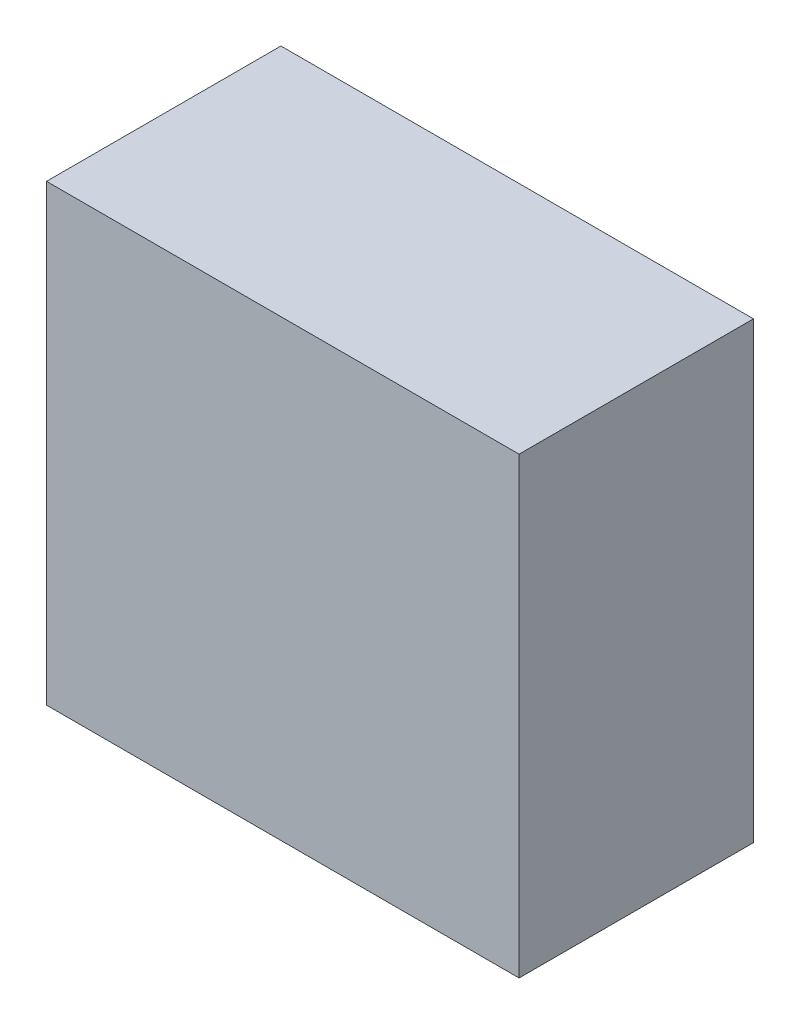
from build123d import *

# Parameters (mm, degrees)
SKETCH1_W           = 3.175
SKETCH1_H           = 1.5748
BOSS_EXTRUDE1_DEPTH = 3.048


with BuildPart() as part:
    # Sketch1 → Boss-Extrude1 (new body)
    with BuildSketch(Plane(origin=(0, 0, 0), x_dir=(1, 0, 0), z_dir=(0, 1, 0))):
        with Locations((1.5875, 0.7874)):
            Rectangle(SKETCH1_W, SKETCH1_H)
    extrude(amount=BOSS_EXTRUDE1_DEPTH)


solid = part.part
